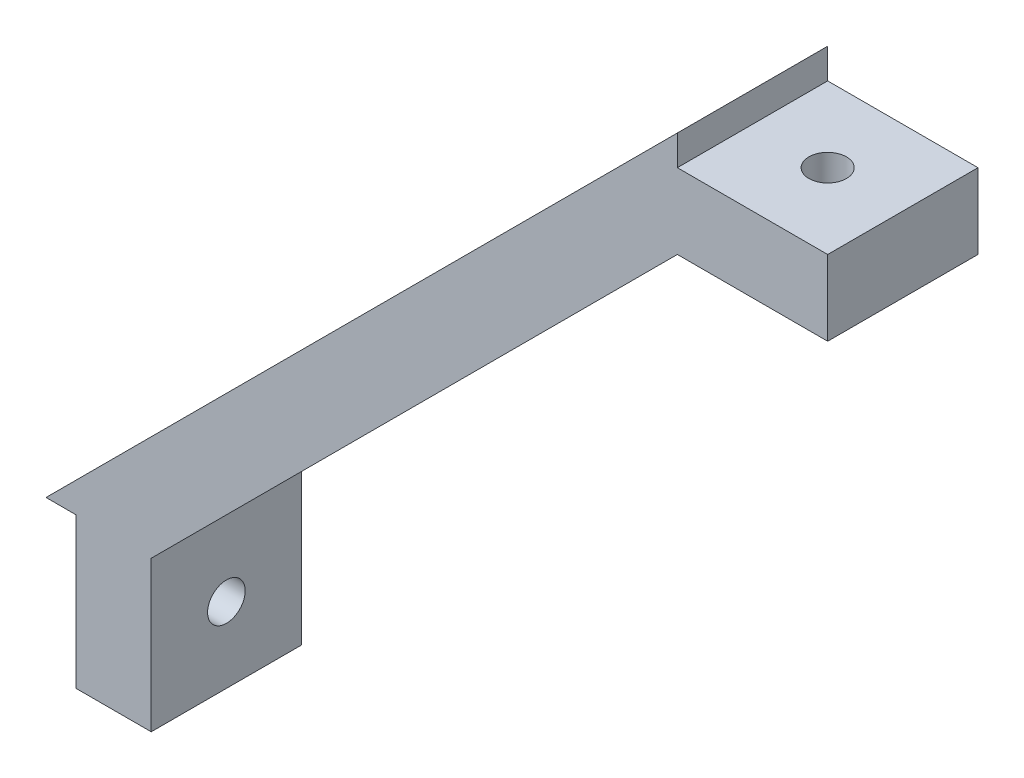
from build123d import *

# Parameters (mm, degrees)
MAIN_DEPTH         = 5
SKETCH2_R          = 1.25
FIXHOLE1_DEPTH     = 43
SKETCH3_R          = 1.25
FIXHOLE2_DEPTH     = 43
SKETCH6_R          = 1.25
CUT_EXTRUDE2_DEPTH = 35.648232278
LPATTERN1_COUNT    = 5
LPATTERN1_PITCH    = 10


with BuildPart() as part:
    # Sketch1 → Main (new body, symmetric)
    with BuildSketch(Plane.XY):
        Polygon((-21, -21), (21, 21), (21, 19), (31, 19), (31, 14), (21, 14), (-14, -21), (-14, -31), (-19, -31), (-19, -21), align=None)
    extrude(amount=MAIN_DEPTH, both=True)

    # Sketch2 → FixHole1 (cut, through all)
    with BuildSketch(Plane(origin=(21, 0, 0), x_dir=(0, 0, -1), z_dir=(1, 0, 0))):
        with Locations((0, -26)):
            Circle(SKETCH2_R)
    extrude(amount=-FIXHOLE1_DEPTH, mode=Mode.SUBTRACT)

    # Sketch3 → FixHole2 (cut, through all)
    with BuildSketch(Plane(origin=(0, -21, 0), x_dir=(-1, 0, 0), z_dir=(0, -1, 0))):
        with Locations((-26, 0)):
            Circle(SKETCH3_R)
    extrude(amount=-FIXHOLE2_DEPTH, mode=Mode.SUBTRACT)

    # Sketch6 → Cut-Extrude2 (cut, through all)
    with BuildSketch(Plane(origin=(3.5, -3.5, 0), x_dir=(0, 0, 1), z_dir=(-0.707106781, 0.707106781, 0))):
        with Locations((0, 20)):
            Circle(SKETCH6_R)
    cut_extrude2 = extrude(amount=CUT_EXTRUDE2_DEPTH, mode=Mode.SUBTRACT)

    # LPattern1: Cut-Extrude2 ×5
    with Locations(*[Vector(-0.707106781, -0.707106781, 0) * (i * LPATTERN1_PITCH) for i in range(1, LPATTERN1_COUNT)]):
        add(cut_extrude2, mode=Mode.SUBTRACT)


solid = part.part
